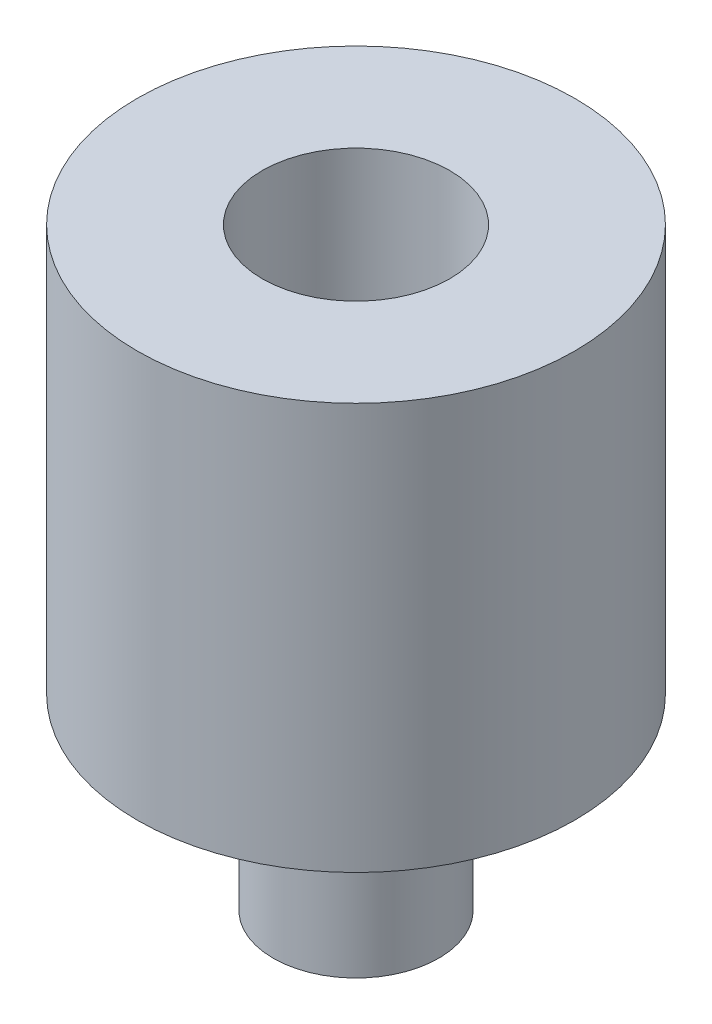
from build123d import *

# Parameters (mm, degrees)
SKETCH1_R           = 1.325
BOSS_EXTRUDE1_DEPTH = 3
SKETCH2_R           = 3.5
BOSS_EXTRUDE2_DEPTH = 1.5
SKETCH3_R           = 3.5
SKETCH3_R_2         = 1.5
BOSS_EXTRUDE3_DEPTH = 5


with BuildPart() as part:
    # Sketch1 → Boss-Extrude1 (new body)
    with BuildSketch(Plane(origin=(0, 0, 0), x_dir=(1, 0, 0), z_dir=(0, 1, 0))):
        Circle(SKETCH1_R)
    extrude(amount=BOSS_EXTRUDE1_DEPTH)

    # Sketch2 → Boss-Extrude2 (add)
    with BuildSketch(Plane(origin=(0, 3, 0), x_dir=(1, 0, 0), z_dir=(0, 1, 0))):
        Circle(SKETCH2_R)
    extrude(amount=BOSS_EXTRUDE2_DEPTH)

    # Sketch3 → Boss-Extrude3 (add)
    with BuildSketch(Plane(origin=(0, 4.5, 0), x_dir=(1, 0, 0), z_dir=(0, 1, 0))):
        Circle(SKETCH3_R)
        Circle(SKETCH3_R_2, mode=Mode.SUBTRACT)
    extrude(amount=BOSS_EXTRUDE3_DEPTH)


solid = part.part
